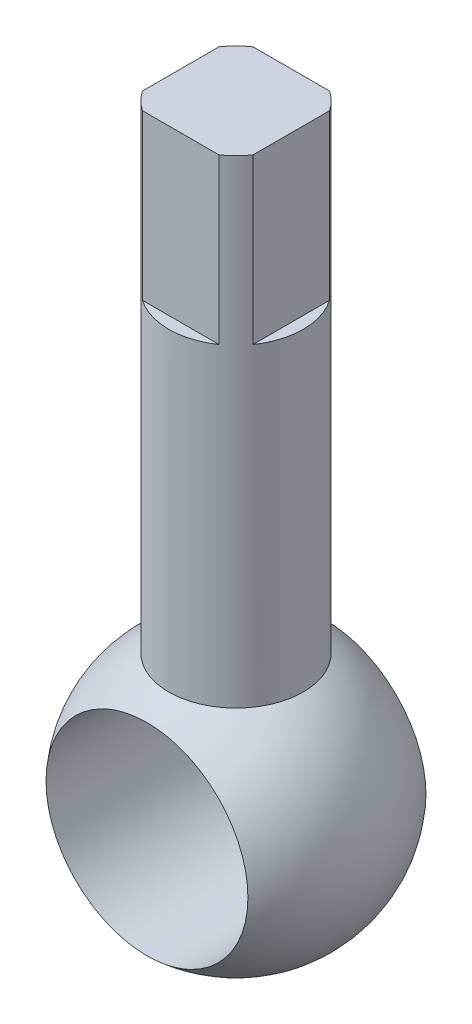
from build123d import *

# Parameters (mm, degrees)
SKETCH3_R               = 19.05
CUT_EXTRUDE1_DEPTH      = 26.4
CUT_EXTRUDE1_DEPTH_BACK = 26.4
SKETCH4_W               = 14.478
SKETCH4_H               = 4.572
CUT_EXTRUDE3_DEPTH      = 30.988
CIRPATTERN2_COUNT       = 4


with BuildPart() as part:
    # Sketch2 → Revolve1 (revolve)
    with BuildSketch(Plane.XY):
        with BuildLine():
            Line((0, 0), (0, 137.668))
            Line((0, 137.668), (-12.7, 137.668))
            Line((-12.7, 137.668), (-12.7, 47.397045256))
            ThreePointArc((-12.7, 47.397045256), (-24.534515988, 18.825996254), (0, 0))
        make_face()
    revolve(axis=Axis((0, 0, 0), (0, 1, 0)))

    # Sketch3 → Cut-Extrude1 (cut, two sides)
    with BuildSketch(Plane.XY) as cut_extrude1_sk:
        with Locations((0, 25.4)):
            Circle(SKETCH3_R)
    extrude(amount=CUT_EXTRUDE1_DEPTH, mode=Mode.SUBTRACT)
    extrude(cut_extrude1_sk.sketch, amount=-CUT_EXTRUDE1_DEPTH_BACK, mode=Mode.SUBTRACT)

    # Sketch4 → Cut-Extrude3 (cut)
    with BuildSketch(Plane(origin=(0, 137.668, 0), x_dir=(1, 0, 0), z_dir=(0, 1, 0))):
        with Locations((0, 12.720887589)):
            Rectangle(SKETCH4_W, SKETCH4_H)
    cut_extrude3 = extrude(amount=-CUT_EXTRUDE3_DEPTH, mode=Mode.SUBTRACT)

    # CirPattern2: Cut-Extrude3 ×4 about axis
    cirpattern2_axis = Axis((0, 0, 0), (0, 1, 0))
    for i in range(1, CIRPATTERN2_COUNT):
        add(cut_extrude3.rotate(cirpattern2_axis, i * 360 / CIRPATTERN2_COUNT), mode=Mode.SUBTRACT)


solid = part.part
